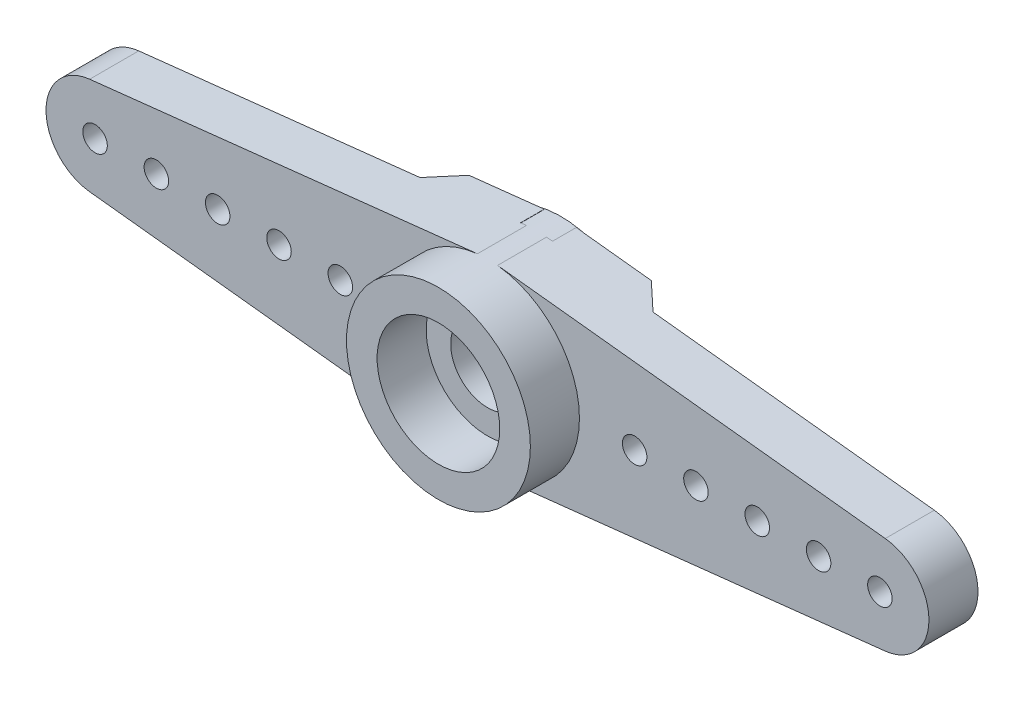
from build123d import *

# Parameters (mm, degrees)
CROQUIS1_R              = 0.5
CROQUIS1_R_2            = 2
CROQUIS1_R_3            = 3.75
CROQUIS1_R_4            = 2.5
CROQUIS1_R_5            = 1.5
SALIENTE_EXTRUIR1_DEPTH = 1
SALIENTE_EXTRUIR2_START = -2
CROQUIS1_3_R            = 3.75
CROQUIS1_3_R_2          = 2.5
SALIENTE_EXTRUIR2_DEPTH = 1
SALIENTE_EXTRUIR3_START = 1
CROQUIS1_4_R            = 3.75
CROQUIS1_4_R_2          = 2.5
SALIENTE_EXTRUIR3_DEPTH = 2
SALIENTE_EXTRUIR5_DEPTH = 0.5
SALIENTE_EXTRUIR6_START = 3.75
SALIENTE_EXTRUIR6_DEPTH = 1
SALIENTE_EXTRUIR7_START = -3.75
SALIENTE_EXTRUIR7_DEPTH = 1
CORTAR_EXTRUIR1_DEPTH   = 3


with BuildPart() as part:
    # Croquis1 → Saliente-Extruir1 (new, symmetric)
    with BuildSketch(Plane.XY):
        with BuildLine():
            ThreePointArc((-0.410156, -3.727502), (-3.75, 0), (-0.410156, 3.727502))
            Line((-0.410156, 3.727502), (-16.21875, 1.988001))
            ThreePointArc((-16.21875, 1.988001), (-14.665365, 1.489547), (-14, 0))
            ThreePointArc((-14, 0), (-14.665365, -1.489547), (-16.21875, -1.988001))
            Line((-16.21875, -1.988001), (-0.410156, -3.727502))
        make_face()
        with BuildLine():
            ThreePointArc((-13, 0), (-13.5, -0.5), (-14, 0))
            ThreePointArc((-14, 0), (-13.5, 0.5), (-13, 0))
        make_face(mode=Mode.SUBTRACT)
        with Locations((-11, 0)):
            Circle(CROQUIS1_R, mode=Mode.SUBTRACT)
        with Locations((-8.5, 0)):
            Circle(CROQUIS1_R, mode=Mode.SUBTRACT)
        with Locations((-6, 0)):
            Circle(CROQUIS1_R, mode=Mode.SUBTRACT)
        with Locations((-16, 0)):
            Circle(CROQUIS1_R_2)
        with Locations((-16, 0)):
            Circle(CROQUIS1_R, mode=Mode.SUBTRACT)
        Circle(CROQUIS1_R_3)
        Circle(CROQUIS1_R_4, mode=Mode.SUBTRACT)
        Circle(CROQUIS1_R_4)
        Circle(CROQUIS1_R_5, mode=Mode.SUBTRACT)
        with BuildLine():
            Line((16.21875, 1.988001), (0.410156, 3.727502))
            ThreePointArc((0.410156, 3.727502), (2.7929, 2.50244), (3.75, 0))
            ThreePointArc((3.75, 0), (2.7929, -2.50244), (0.410156, -3.727502))
            Line((0.410156, -3.727502), (16.21875, -1.988001))
            ThreePointArc((16.21875, -1.988001), (14.665365, -1.489547), (14, 0))
            ThreePointArc((14, 0), (14.665365, 1.489547), (16.21875, 1.988001))
        make_face()
        with Locations((6, 0)):
            Circle(CROQUIS1_R, mode=Mode.SUBTRACT)
        with Locations((8.5, 0)):
            Circle(CROQUIS1_R, mode=Mode.SUBTRACT)
        with Locations((11, 0)):
            Circle(CROQUIS1_R, mode=Mode.SUBTRACT)
        with Locations((13.5, 0)):
            Circle(CROQUIS1_R, mode=Mode.SUBTRACT)
        with Locations((16, 0)):
            Circle(CROQUIS1_R_2)
        with Locations((16, 0)):
            Circle(CROQUIS1_R, mode=Mode.SUBTRACT)
    extrude(amount=SALIENTE_EXTRUIR1_DEPTH, both=True)

    # Croquis1_3 → Saliente-Extruir2 (add)
    with BuildSketch(Plane.XY.offset(SALIENTE_EXTRUIR2_START)):
        with Locations(Location((0, 0, 0), (0, 0, 263.720712))):
            Circle(CROQUIS1_3_R)
        Circle(CROQUIS1_3_R_2, mode=Mode.SUBTRACT)
    extrude(amount=SALIENTE_EXTRUIR2_DEPTH)

    # Croquis1_4 → Saliente-Extruir3 (add)
    with BuildSketch(Plane.XY.offset(SALIENTE_EXTRUIR3_START)):
        Circle(CROQUIS1_4_R)
        Circle(CROQUIS1_4_R_2, mode=Mode.SUBTRACT)
    extrude(amount=SALIENTE_EXTRUIR3_DEPTH)

    # Croquis3 → Saliente-Extruir5 (add, symmetric)
    with BuildSketch(Plane(origin=(0, 0, 0), x_dir=(1, 0, 0), z_dir=(0, 1, 0))):
        Polygon((-4.75, 1), (-3.678391, 2), (-3.678391, 1), align=None)
        Polygon((3.678391, 1), (4.75, 1), (3.678391, 2), align=None)
    extrude(amount=SALIENTE_EXTRUIR5_DEPTH, both=True)

    # Croquis4 → Saliente-Extruir6 (add)
    with BuildSketch(Plane(origin=(0, 0, 0), x_dir=(1, 0, 0), z_dir=(0, 1, 0)).offset(SALIENTE_EXTRUIR6_START)):
        Polygon((-4.75, 1), (-0.650356, 1), (-0.650356, 1.964422), (-3.716517, 1.964422), align=None)
        Polygon((0.650356, 1.964422), (0.650356, 1), (4.75, 1), (3.716517, 1.964422), align=None)
    extrude(amount=-SALIENTE_EXTRUIR6_DEPTH)

    # Croquis4_2 → Saliente-Extruir7 (add)
    with BuildSketch(Plane(origin=(0, 0, 0), x_dir=(1, 0, 0), z_dir=(0, 1, 0)).offset(SALIENTE_EXTRUIR7_START)):
        Polygon((-4.75, 1), (-0.650356, 1), (-0.650356, 1.964422), (-3.716517, 1.964422), align=None)
        Polygon((0.650356, 1.964422), (0.650356, 1), (4.75, 1), (3.716517, 1.964422), align=None)
    extrude(amount=SALIENTE_EXTRUIR7_DEPTH)

    # Croquis5 → Cortar-Extruir1 (cut)
    with BuildSketch(Plane.XY.offset(-1)):
        Polygon((0.650356, -3.75), (4.75, -3.75), (4.75, -3.249967), (0.650356, -3.701072), align=None)
        Polygon((-0.650356, -3.701072), (-0.650356, -3.75), (-4.75, -3.75), (-4.75, -3.249967), align=None)
        Polygon((-4.75, 3.75), (-4.75, 3.249967), (-0.650356, 3.701072), (-0.650356, 3.75), align=None)
        Polygon((0.650356, 3.701072), (0.650356, 3.75), (4.75, 3.75), (4.75, 3.249967), align=None)
    extrude(amount=-CORTAR_EXTRUIR1_DEPTH, mode=Mode.SUBTRACT)


solid = part.part
